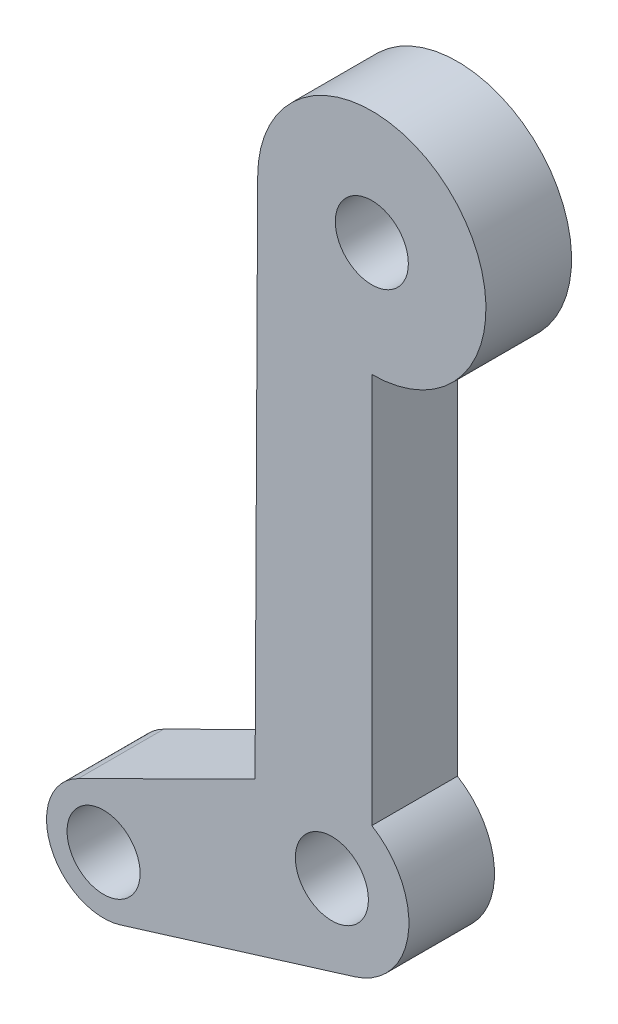
from build123d import *

# Parameters (mm, degrees)
SKETCH1_R           = 1.6
BOSS_EXTRUDE1_DEPTH = 3.75


with BuildPart() as part:
    # Sketch1 → Boss-Extrude1 (new body)
    with BuildSketch(Plane.XY):
        with BuildLine():
            Line((0, -22.114150905), (0, -5))
            ThreePointArc((0, -5), (3.535533906, 3.535533906), (-5, 0))
            Line((-5, 0), (-5.114562262, -22.904716871))
            Line((-5.114562262, -22.904716871), (-12.863985131, -26.761912172))
            ThreePointArc((-12.863985131, -26.761912172), (-14.071191727, -29.928476691), (-11.013170041, -31.388949897))
            Line((-11.013170041, -31.388949897), (-0.755279555, -28.225082361))
            ThreePointArc((-0.755279555, -28.225082361), (1.599513904, -25.413982613), (0, -22.114150905))
        make_face()
        Circle(SKETCH1_R, mode=Mode.SUBTRACT)
        with Locations((-1.75, -25)):
            Circle(SKETCH1_R, mode=Mode.SUBTRACT)
        with Locations((-11.75, -29)):
            Circle(SKETCH1_R, mode=Mode.SUBTRACT)
    extrude(amount=BOSS_EXTRUDE1_DEPTH)


solid = part.part
